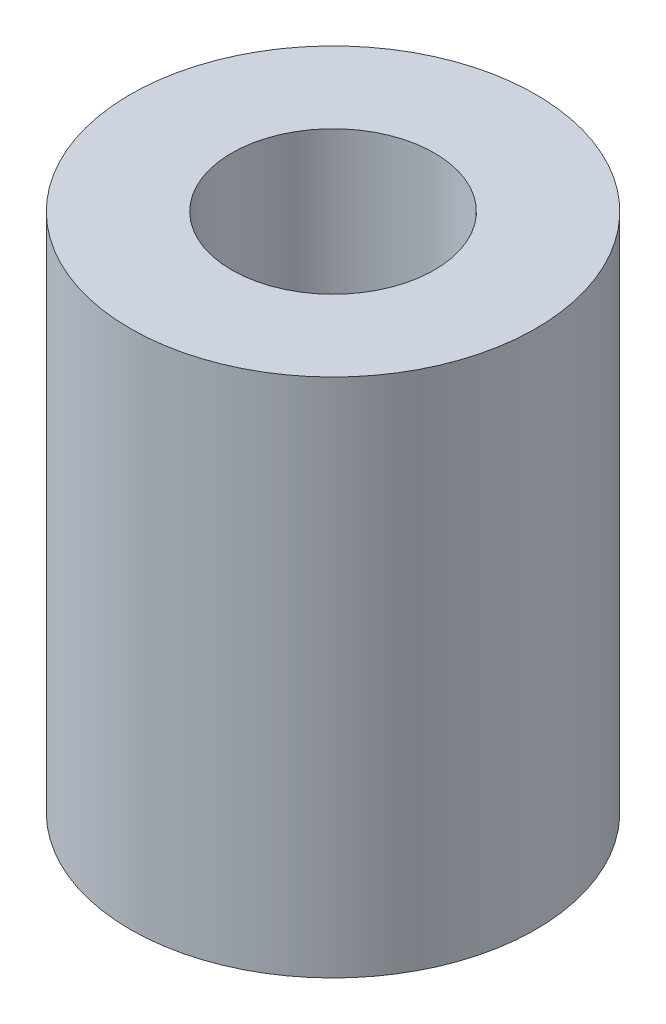
from build123d import *

# Parameters (mm, degrees)
SKETCH1_R           = 3
SKETCH1_R_2         = 1.5
BOSS_EXTRUDE1_DEPTH = 7.7


with BuildPart() as part:
    # Sketch1 → Boss-Extrude1 (new body)
    with BuildSketch(Plane(origin=(0, 0, 0), x_dir=(1, 0, 0), z_dir=(0, 1, 0))):
        Circle(SKETCH1_R)
        Circle(SKETCH1_R_2, mode=Mode.SUBTRACT)
    extrude(amount=BOSS_EXTRUDE1_DEPTH)


solid = part.part
